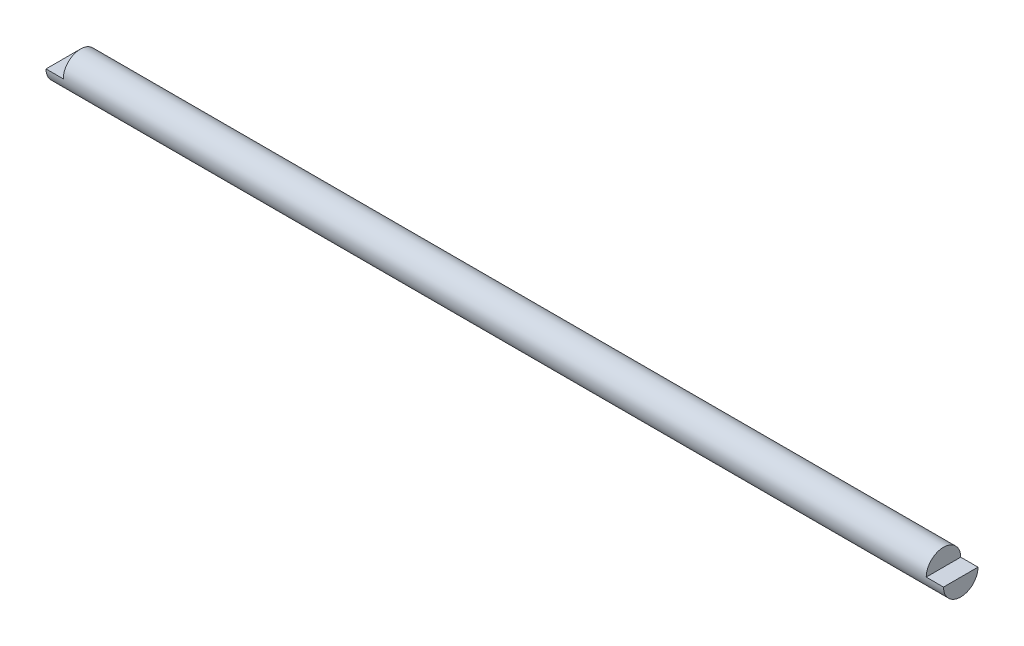
from build123d import *

# Parameters (mm, degrees)
SKETCH1_R               = 6.35
BOSS_EXTRUDE1_DEPTH     = 330.2
SKETCH2_W               = 6.35
SKETCH2_H               = 6.35
CUT_EXTRUDE1_DEPTH      = 7.35
CUT_EXTRUDE1_DEPTH_BACK = 7.35


with BuildPart() as part:
    # Sketch1 → Boss-Extrude1 (new body)
    with BuildSketch(Plane(origin=(0, 0, 0), x_dir=(0, 0, -1), z_dir=(1, 0, 0))):
        Circle(SKETCH1_R)
    extrude(amount=BOSS_EXTRUDE1_DEPTH)

    # Sketch2 → Cut-Extrude1 (cut, two sides)
    with BuildSketch(Plane.XY) as cut_extrude1_sk:
        with Locations((3.175, 3.175)):
            Rectangle(SKETCH2_W, SKETCH2_H)
        with Locations((327.025, 3.175)):
            Rectangle(SKETCH2_W, SKETCH2_H)
    extrude(amount=CUT_EXTRUDE1_DEPTH, mode=Mode.SUBTRACT)
    extrude(cut_extrude1_sk.sketch, amount=-CUT_EXTRUDE1_DEPTH_BACK, mode=Mode.SUBTRACT)


solid = part.part
